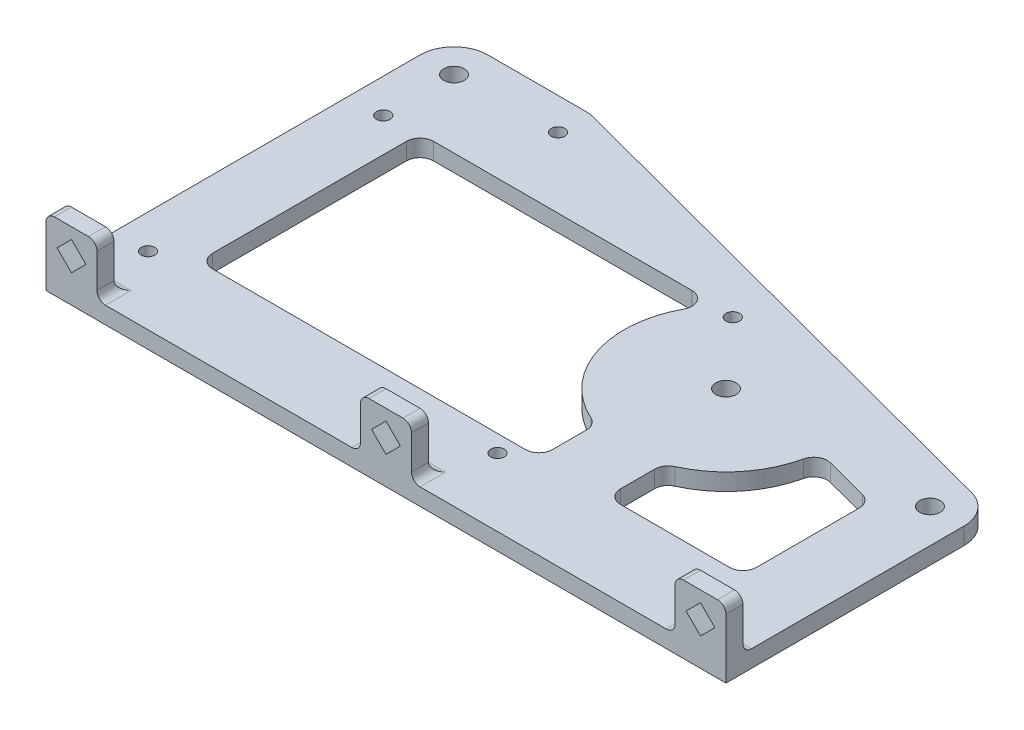
from build123d import *

# Parameters (mm, degrees)
SKETCH1_R           = 1.905
SKETCH1_R_2         = 1.27
BOSS_EXTRUDE1_DEPTH = 3.175
SKETCH2_R           = 1.27
CUT_EXTRUDE1_DEPTH  = 3.175
FILLET1_R           = 6.35
SKETCH3_W           = 9.525
SKETCH3_H           = 9.525
BOSS_EXTRUDE2_DEPTH = 3.175
FILLET2_R           = 1.5875


with BuildPart() as part:
    # Sketch1 → Boss-Extrude1 (new body)
    with BuildSketch(Plane(origin=(0, 0, 0), x_dir=(1, 0, 0), z_dir=(0, 1, 0))):
        Polygon((-82.55, 31.75), (-82.55, -44.45), (44.45, -44.45), (44.45, 4.889379277), (-57.15, 31.75), align=None)
        Circle(SKETCH1_R, mode=Mode.SUBTRACT)
        with Locations((-57.15, 25.774227063)):
            Circle(SKETCH1_R_2, mode=Mode.SUBTRACT)
        with Locations((-76.2, 25.4)):
            Circle(SKETCH1_R, mode=Mode.SUBTRACT)
        with Locations((38.1, 0)):
            Circle(SKETCH1_R, mode=Mode.SUBTRACT)
    extrude(amount=BOSS_EXTRUDE1_DEPTH)

    # Sketch2 → Cut-Extrude1 (cut)
    with BuildSketch(Plane(origin=(0, 3.175, 0), x_dir=(1, 0, 0), z_dir=(0, 1, 0))):
        with Locations((-76.2, 12.192)):
            Circle(SKETCH2_R)
        with Locations((-10.922, 12.192)):
            Circle(SKETCH2_R)
        with Locations((-10.922, -31.75)):
            Circle(SKETCH2_R)
        with Locations((-76.2, -31.75)):
            Circle(SKETCH2_R)
        with BuildLine():
            Line((-69.85, 10.16), (-69.85, -26.035))
            ThreePointArc((-69.85, -26.035), (-69.106051224, -27.831051224), (-67.31, -28.575))
            Line((-67.31, -28.575), (-8.89, -28.575))
            ThreePointArc((-8.89, -28.575), (-7.093948776, -27.831051224), (-6.35, -26.035))
            Line((-6.35, -26.035), (-6.35, -19.674755399))
            ThreePointArc((-6.35, -19.674755399), (-6.755973152, -18.297246992), (-7.844117647, -17.360078293))
            ThreePointArc((-7.844117647, -17.360078293), (-18.033037532, -6.14101436), (-16.808823529, 8.964705882))
            ThreePointArc((-16.808823529, 8.964705882), (-16.871967969, 11.466819219), (-19.05, 12.7))
            Line((-19.05, 12.7), (-67.31, 12.7))
            ThreePointArc((-67.31, 12.7), (-69.106051224, 11.956051224), (-69.85, 10.16))
        make_face()
        with BuildLine():
            Line((6.35, -19.674755399), (6.35, -26.035))
            ThreePointArc((6.35, -26.035), (7.093948776, -27.831051224), (8.89, -28.575))
            Line((8.89, -28.575), (29.21, -28.575))
            ThreePointArc((29.21, -28.575), (31.006051224, -27.831051224), (31.75, -26.035))
            Line((31.75, -26.035), (31.75, -6.845130987))
            ThreePointArc((31.75, -6.845130987), (31.222535045, -5.295517264), (29.859210479, -4.38949955))
            Line((29.859210479, -4.38949955), (21.722749497, -2.23841301))
            ThreePointArc((21.722749497, -2.23841301), (19.753320798, -2.524108077), (18.594299133, -4.141803924))
            ThreePointArc((18.594299133, -4.141803924), (14.779315437, -12.019747718), (7.844117647, -17.360078293))
            ThreePointArc((7.844117647, -17.360078293), (6.755973152, -18.297246992), (6.35, -19.674755399))
        make_face()
    extrude(amount=-CUT_EXTRUDE1_DEPTH, mode=Mode.SUBTRACT)

    # Fillet1
    fillet1_edges = [part.edges().sort_by_distance(p)[0] for p in [
        (-57.15, 1.5875, -31.75),
        (44.45, 1.5875, -4.889379277),
        (-82.55, 1.5875, -31.75),
    ]]
    fillet(fillet1_edges, radius=FILLET1_R)

    # Sketch3 → Boss-Extrude2 (add)
    with BuildSketch(Plane.XY.offset(44.45)):
        with Locations((-77.7875, 7.9375)):
            Rectangle(SKETCH3_W, SKETCH3_H)
        Polygon((-77.7875, 5.243423164), (-75.093423164, 7.9375), (-77.7875, 10.631576836), (-80.481576836, 7.9375), align=None, mode=Mode.SUBTRACT)
        with Locations((39.6875, 7.9375)):
            Rectangle(SKETCH3_W, SKETCH3_H)
        Polygon((39.6875, 5.243423164), (42.381576836, 7.9375), (39.6875, 10.631576836), (36.993423164, 7.9375), align=None, mode=Mode.SUBTRACT)
        with Locations((-19.05, 7.9375)):
            Rectangle(SKETCH3_W, SKETCH3_H)
        Polygon((-19.05, 5.243423164), (-16.355923164, 7.9375), (-19.05, 10.631576836), (-21.744076836, 7.9375), align=None, mode=Mode.SUBTRACT)
    extrude(amount=-BOSS_EXTRUDE2_DEPTH)

    # Fillet2
    fillet2_edges = [part.edges().sort_by_distance(p)[0] for p in [
        (-82.55, 12.7, 42.8625),
        (-73.025, 12.7, 42.8625),
        (-77.7875, 3.175, 41.275),
        (-73.025, 3.175, 42.8625),
        (44.45, 12.7, 42.8625),
        (39.6875, 3.175, 41.275),
        (34.925, 3.175, 42.8625),
        (34.925, 12.7, 42.8625),
        (-23.8125, 3.175, 42.8625),
        (-23.8125, 12.7, 42.8625),
        (-14.2875, 12.7, 42.8625),
        (-19.05, 3.175, 41.275),
        (-14.2875, 3.175, 42.8625),
    ]]
    fillet(fillet2_edges, radius=FILLET2_R)


solid = part.part
